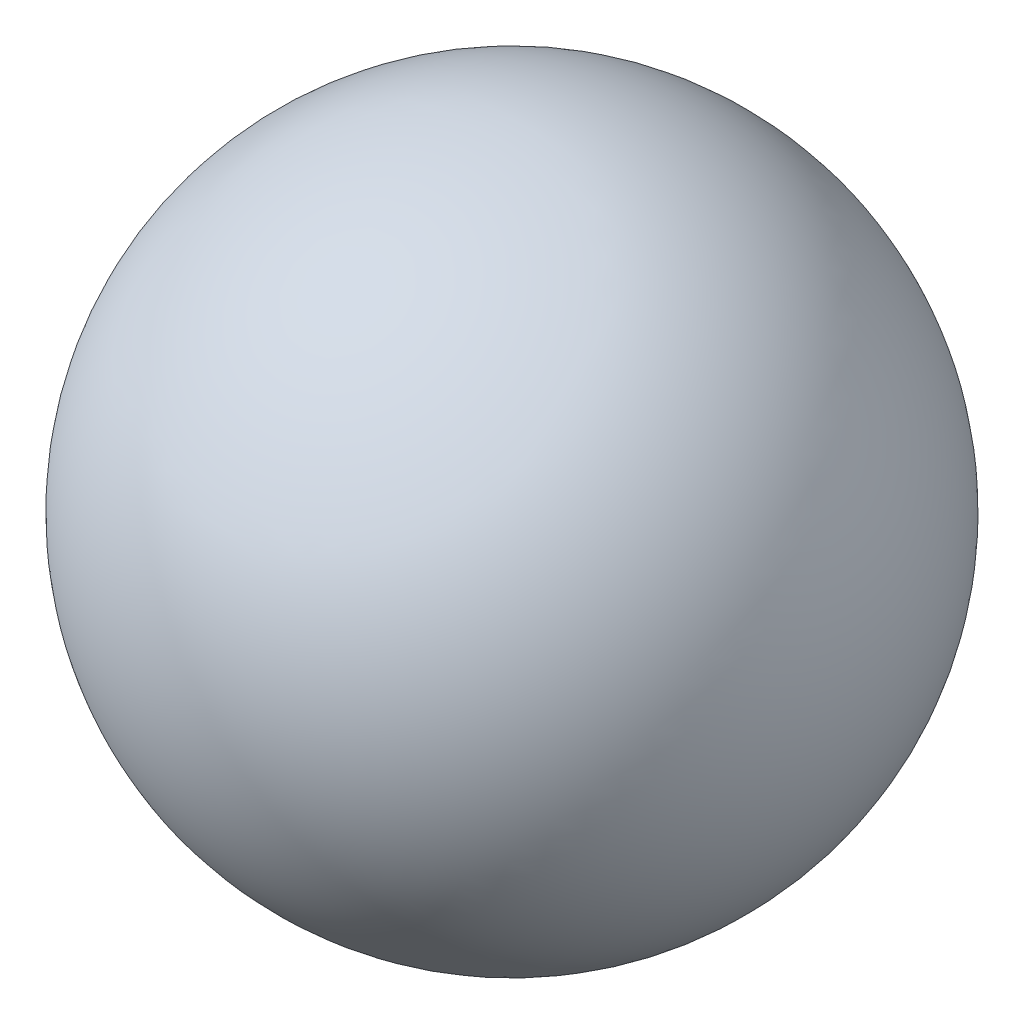
from build123d import *


with BuildPart() as part:
    # Sketch1 → Revolve3 (revolve)
    with BuildSketch(Plane(origin=(0, 0, 0), x_dir=(1, 0, 0), z_dir=(0, 1, 0))):
        with BuildLine():
            Line((0, 20), (0, -20))
            ThreePointArc((0, -20), (-20, 0), (0, 20))
        make_face()
    revolve(axis=Axis((0, 0, -20), (0, 0, 1)))


solid = part.part
